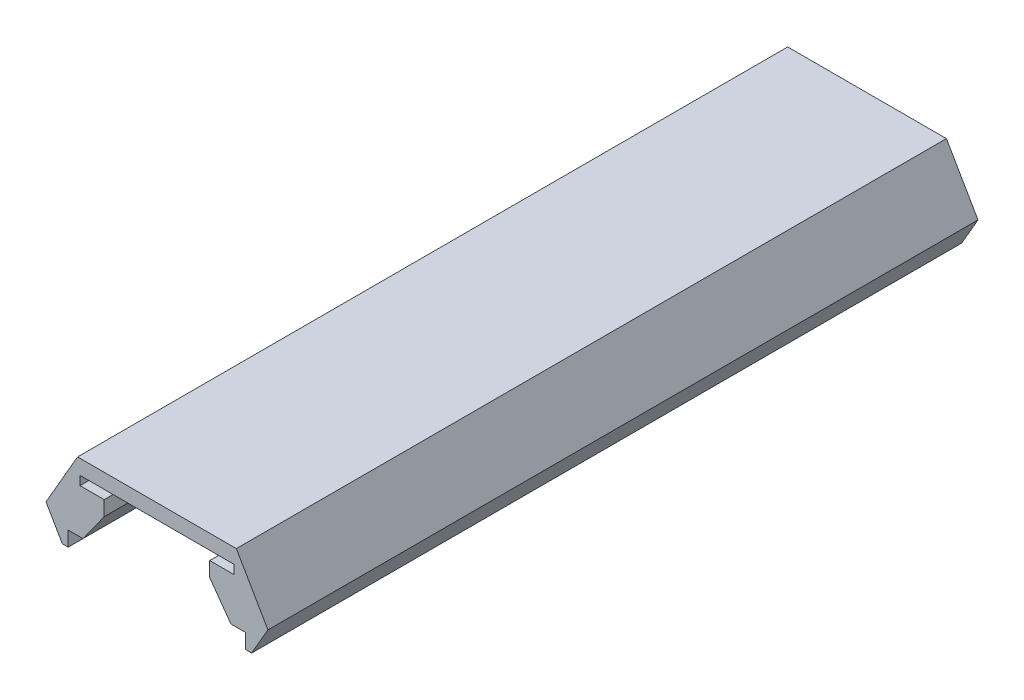
from build123d import *

# Parameters (mm, degrees)
BOSS_EXTRUDE1_DEPTH = 24


with BuildPart() as part:
    # Sketch2 → Boss-Extrude1 (new body, symmetric)
    with BuildSketch(Plane.XY):
        Polygon((7.5, -2.694744112), (5.366838493, 1), (-5.366838493, 1), (-7.5, -2.694744112), (-6.4, -4.6), (-6, -4.6), (-6, -3.6), (-5, -3.6), (-3.56692895, -1.6), (-3.56692895, -0.6), (-5.2, -0.6), (-5.2, 0), (5.2, 0), (5.2, -0.6), (3.56692895, -0.6), (3.56692895, -1.6), (5, -3.6), (6, -3.6), (6, -4.6), (6.4, -4.6), align=None)
    extrude(amount=BOSS_EXTRUDE1_DEPTH, both=True)


solid = part.part
